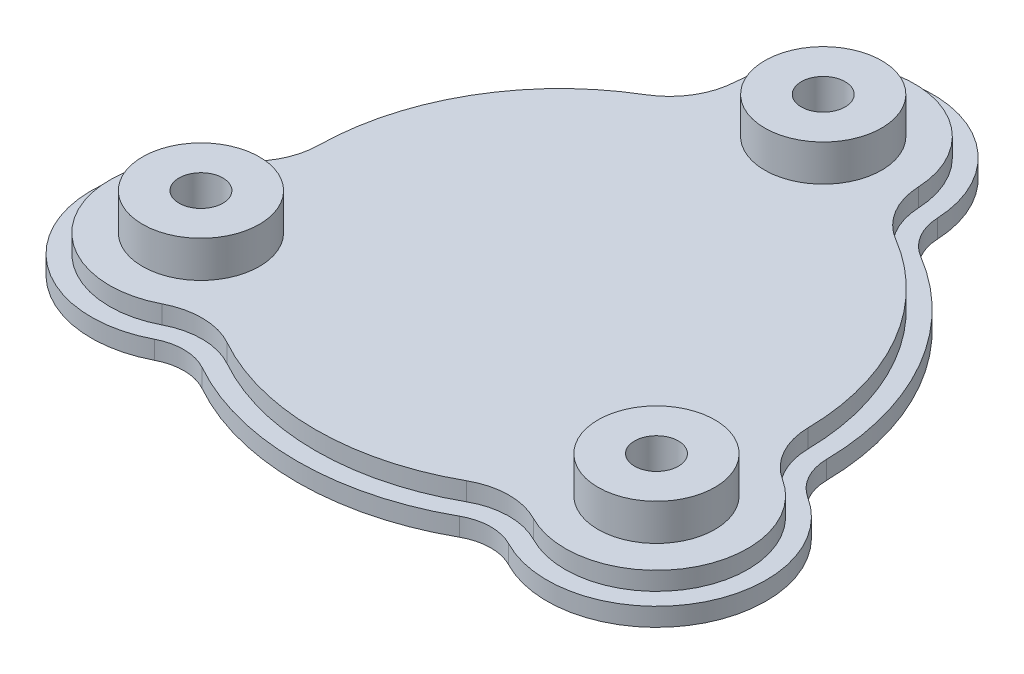
from build123d import *

# Parameters (mm, degrees)
BOSS_EXTRUDE1_DEPTH = 2.5
BOSS_EXTRUDE2_DEPTH = 2.5
SKETCH3_R           = 8
SKETCH3_R_2         = 3
BOSS_EXTRUDE3_DEPTH = 5
SKETCH4_R           = 5.5
CUT_EXTRUDE1_DEPTH  = 5


with BuildPart() as part:
    # Sketch1 → Boss-Extrude1 (new body)
    with BuildSketch(Plane(origin=(0, 0, 0), x_dir=(1, 0, 0), z_dir=(0, 1, 0))):
        with BuildLine():
            ThreePointArc((-18.401121459, 30.941860465), (-31.176914536, 18), (-35.996997933, 0.464908409))
            ThreePointArc((-35.996997933, 0.464908409), (-36.88129594, -2.851352197), (-39.235664305, -5.348654136))
            ThreePointArc((-39.235664305, -5.348654136), (-44.167295593, -25.5), (-24.249902511, -31.304754955))
            ThreePointArc((-24.249902511, -31.304754955), (-20.909991408, -30.51446311), (-17.595876474, -31.406768874))
            ThreePointArc((-17.595876474, -31.406768874), (0, -36), (17.595876474, -31.406768874))
            ThreePointArc((17.595876474, -31.406768874), (20.909991408, -30.51446311), (24.249902511, -31.304754955))
            ThreePointArc((24.249902511, -31.304754955), (44.167295593, -25.5), (39.235664305, -5.348654136))
            ThreePointArc((39.235664305, -5.348654136), (36.88129594, -2.851352197), (35.996997933, 0.464908409))
            ThreePointArc((35.996997933, 0.464908409), (31.176914536, 18), (18.401121459, 30.941860465))
            ThreePointArc((18.401121459, 30.941860465), (15.971304532, 33.365815307), (14.985761794, 36.653409091))
            ThreePointArc((14.985761794, 36.653409091), (0, 51), (-14.985761794, 36.653409091))
            ThreePointArc((-14.985761794, 36.653409091), (-15.971304532, 33.365815307), (-18.401121459, 30.941860465))
        make_face()
    extrude(amount=BOSS_EXTRUDE1_DEPTH)

    # Sketch2 → Boss-Extrude2 (add)
    with BuildSketch(Plane(origin=(0, 2.5, 0), x_dir=(1, 0, 0), z_dir=(0, 1, 0))):
        with BuildLine():
            ThreePointArc((33.49720641, 0.432623103), (34.697325134, -4.068016291), (37.892539344, -7.45721178))
            ThreePointArc((37.892539344, -7.45721178), (42.002232084, -24.25), (25.404404515, -29.087295795))
            ThreePointArc((25.404404515, -29.087295795), (20.871668018, -28.014756864), (16.373940607, -29.225743258))
            ThreePointArc((16.373940607, -29.225743258), (0, -33.5), (-16.373940607, -29.225743258))
            ThreePointArc((-16.373940607, -29.225743258), (-20.871668018, -28.014756864), (-25.404404515, -29.087295795))
            ThreePointArc((-25.404404515, -29.087295795), (-42.002232084, -24.25), (-37.892539344, -7.45721178))
            ThreePointArc((-37.892539344, -7.45721178), (-34.697325134, -4.068016291), (-33.49720641, 0.432623103))
            ThreePointArc((-33.49720641, 0.432623103), (-29.011851027, 16.75), (-17.123265802, 28.793120155))
            ThreePointArc((-17.123265802, 28.793120155), (-13.825657116, 32.082773155), (-12.488134829, 36.544507576))
            ThreePointArc((-12.488134829, 36.544507576), (0, 48.5), (12.488134829, 36.544507576))
            ThreePointArc((12.488134829, 36.544507576), (13.825657116, 32.082773155), (17.123265802, 28.793120155))
            ThreePointArc((17.123265802, 28.793120155), (29.011851027, 16.75), (33.49720641, 0.432623103))
        make_face()
    extrude(amount=BOSS_EXTRUDE2_DEPTH)

    # Sketch3 → Boss-Extrude3 (add)
    with BuildSketch(Plane(origin=(0, 5, 0), x_dir=(1, 0, 0), z_dir=(0, 1, 0))):
        with Locations((0, 36)):
            Circle(SKETCH3_R)
        with Locations((0, 36)):
            Circle(SKETCH3_R_2, mode=Mode.SUBTRACT)
        with Locations((31.176914536, -18)):
            Circle(SKETCH3_R)
        with Locations((31.176914536, -18)):
            Circle(SKETCH3_R_2, mode=Mode.SUBTRACT)
        with Locations((-31.176914536, -18)):
            Circle(SKETCH3_R)
        with Locations((-31.176914536, -18)):
            Circle(SKETCH3_R_2, mode=Mode.SUBTRACT)
    extrude(amount=BOSS_EXTRUDE3_DEPTH)

    # Sketch4 → Cut-Extrude1 (cut)
    with BuildSketch(Plane.XZ):
        with Locations((31.176914536, 18)):
            Circle(SKETCH4_R)
        with Locations((0, -36)):
            Circle(SKETCH4_R)
        with Locations((-31.176914536, 18)):
            Circle(SKETCH4_R)
    extrude(amount=-CUT_EXTRUDE1_DEPTH, mode=Mode.SUBTRACT)


solid = part.part
